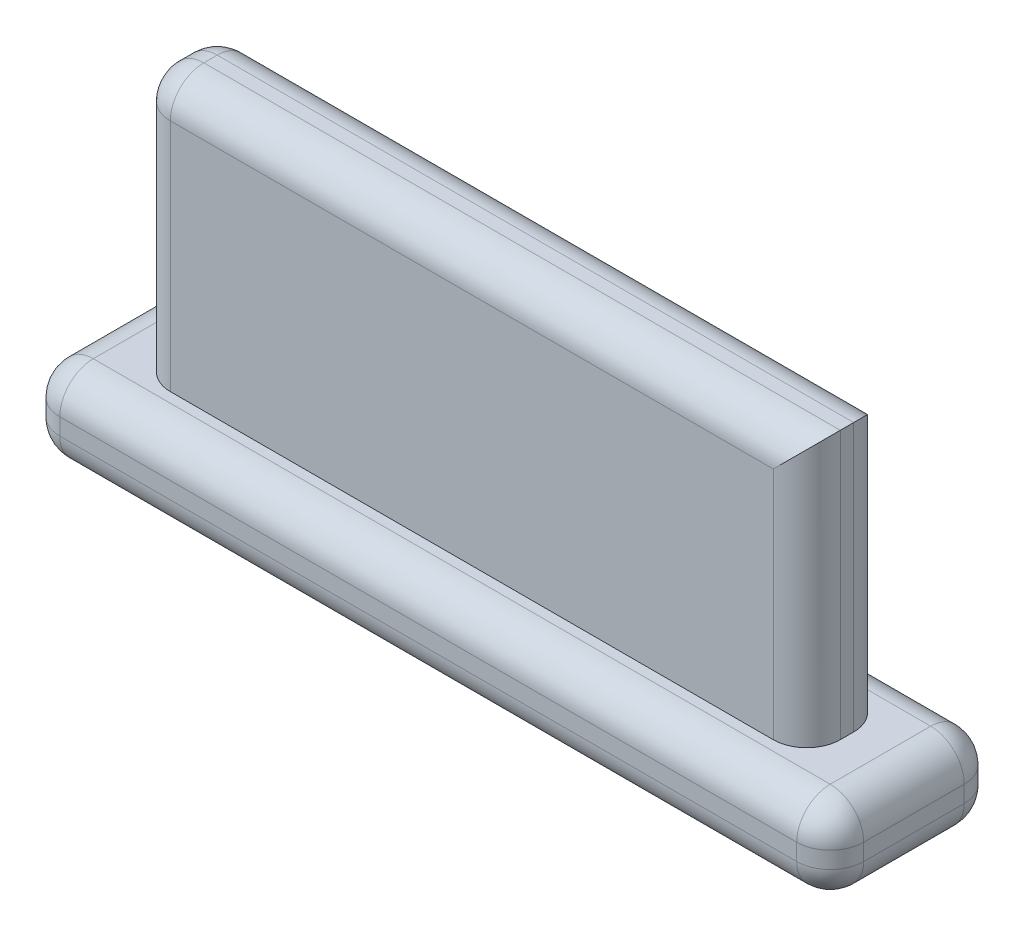
from build123d import *

# Parameters (mm, degrees)
SKETCH1_W           = 25.4
SKETCH1_H           = 3.048
BOSS_EXTRUDE1_DEPTH = 10.16
SKETCH2_W           = 30.48
SKETCH2_H           = 6.35
BOSS_EXTRUDE2_DEPTH = 3.175
FILLET1_R           = 1.27


with BuildPart() as part:
    # Sketch1 → Boss-Extrude1 (new body)
    with BuildSketch(Plane(origin=(0, 0, 0), x_dir=(1, 0, 0), z_dir=(0, 1, 0))):
        Rectangle(SKETCH1_W, SKETCH1_H)
    extrude(amount=BOSS_EXTRUDE1_DEPTH)

    # Sketch2 → Boss-Extrude2 (add)
    with BuildSketch(Plane.XZ):
        Rectangle(SKETCH2_W, SKETCH2_H)
    extrude(amount=BOSS_EXTRUDE2_DEPTH)

    # Fillet1
    fillet1_edges = [part.edges().sort_by_distance(p)[0] for p in [
        (-12.7, 10.16, 0),
        (15.24, 0, 0),
        (15.24, -1.5875, -3.175),
        (0, 0, 3.175),
        (15.24, -1.5875, 3.175),
        (-15.24, 0, 0),
        (-15.24, -1.5875, 3.175),
        (0, 0, -3.175),
        (-15.24, -1.5875, -3.175),
        (15.24, -3.175, 0),
        (0, -3.175, 3.175),
        (-15.24, -3.175, 0),
        (0, 10.16, 1.524),
        (0, -3.175, -3.175),
        (12.7, 5.08, 1.524),
        (-12.7, 5.08, 1.524),
        (-12.7, 5.08, -1.524),
        (12.7, 5.08, -1.524),
        (0, 10.16, -1.524),
    ]]
    fillet(fillet1_edges, radius=FILLET1_R)


solid = part.part
